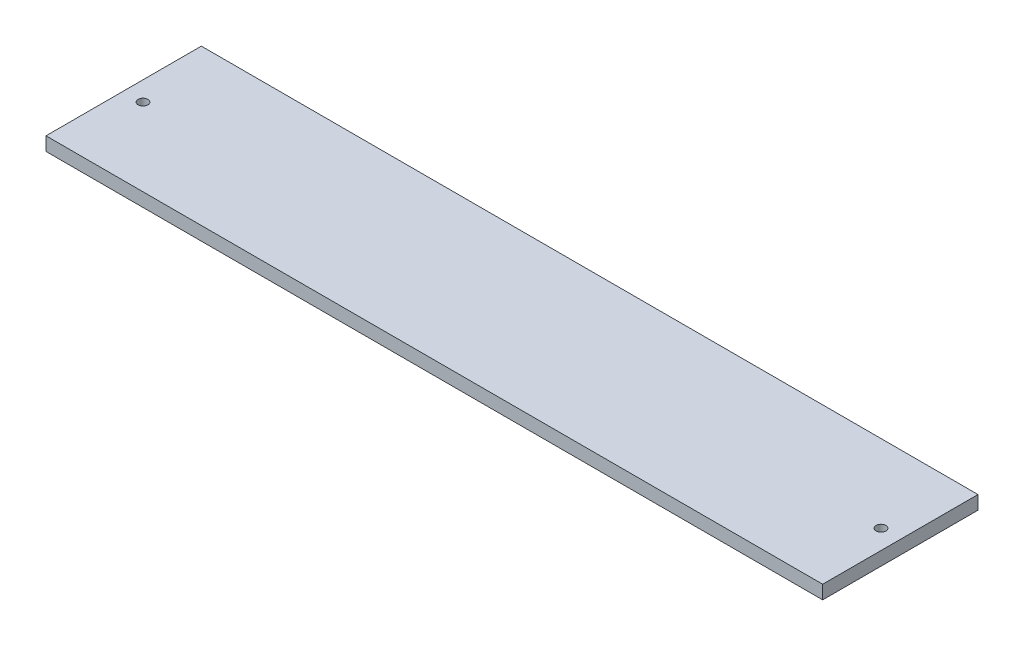
from build123d import *

# Parameters (mm, degrees)
SCHIZZO1_W                   = 400
SCHIZZO1_H                   = 80
ESTRUSIONE_ESTRUSIONE1_DEPTH = 7
SCHIZZO2_R                   = 2.5
TAGLIO_ESTRUSIONE1_DEPTH     = 10


with BuildPart() as part:
    # Schizzo1 → Estrusione-Estrusione1 (new body)
    with BuildSketch(Plane(origin=(0, 0, 0), x_dir=(1, 0, 0), z_dir=(0, 1, 0))):
        with Locations((200, 40)):
            Rectangle(SCHIZZO1_W, SCHIZZO1_H)
    extrude(amount=ESTRUSIONE_ESTRUSIONE1_DEPTH)

    # Schizzo2 → Taglio-Estrusione1 (cut)
    with BuildSketch(Plane(origin=(109.673515981, 0, 372.376145612), x_dir=(0, 0, 1), z_dir=(0, -1, 0))):
        with Locations((-412.376145611, 99.718426121)):
            Circle(SCHIZZO2_R)
        with Locations((-412.376145611, -280.371394158)):
            Circle(SCHIZZO2_R)
    extrude(amount=-TAGLIO_ESTRUSIONE1_DEPTH, mode=Mode.SUBTRACT)


solid = part.part
